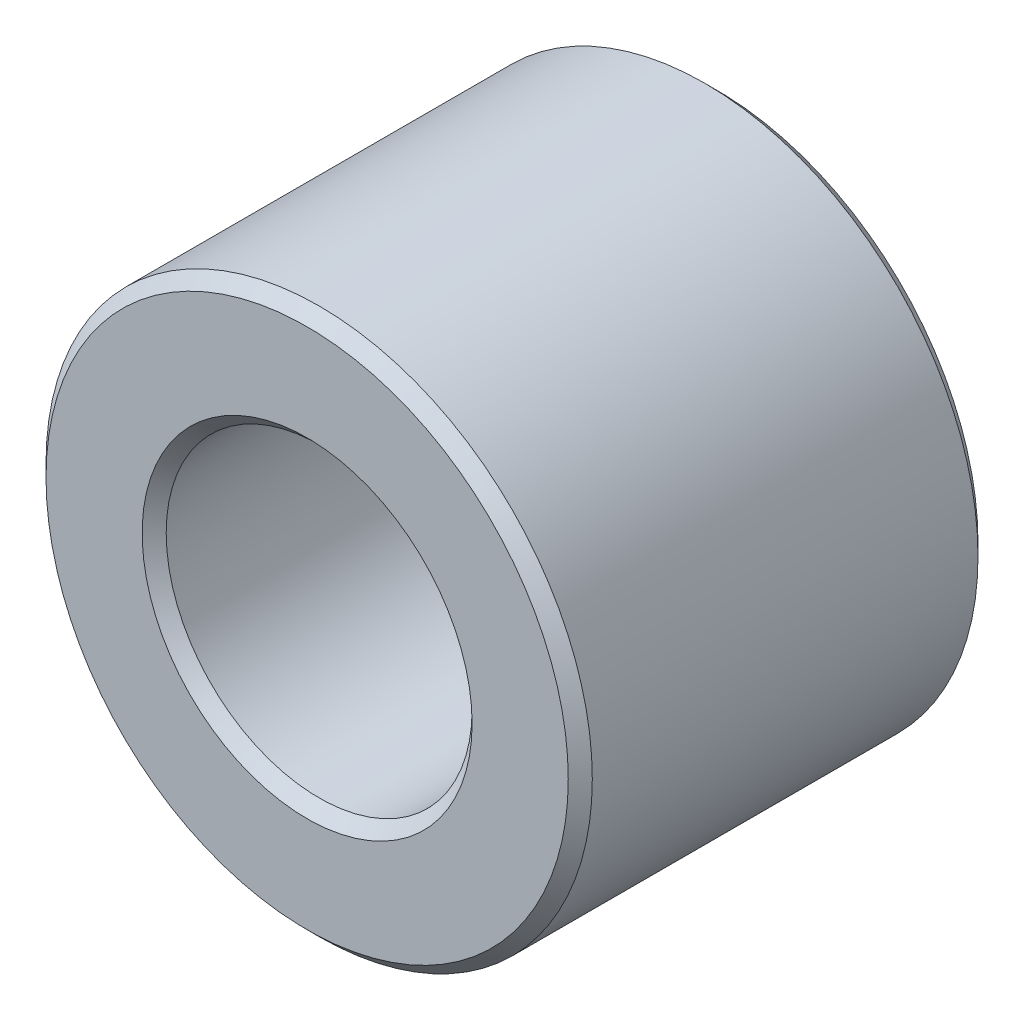
from build123d import *

# Parameters (mm, degrees)
SKETCH3_R                = 3.175
SKETCH3_R_2              = 1.778
BOSS_EXTRUDE1_DEPTH      = 2.38125
BOSS_EXTRUDE1_DEPTH_BACK = 2.38125
CHAMFER1_SIZE            = 0.1397


with BuildPart() as part:
    # Sketch3 → Boss-Extrude1 (new body, two sides)
    with BuildSketch(Plane.XY) as boss_extrude1_sk:
        Circle(SKETCH3_R)
        Circle(SKETCH3_R_2, mode=Mode.SUBTRACT)
    extrude(amount=BOSS_EXTRUDE1_DEPTH)
    extrude(boss_extrude1_sk.sketch, amount=-BOSS_EXTRUDE1_DEPTH_BACK)

    # Chamfer1
    chamfer1_edges = [part.edges().sort_by_distance(p)[0] for p in [
        (-3.175, 0, -2.38125),
        (-1.778, 0, -2.38125),
        (-3.175, 0, 2.38125),
        (-1.778, 0, 2.38125),
    ]]
    chamfer(chamfer1_edges, length=CHAMFER1_SIZE)


solid = part.part
